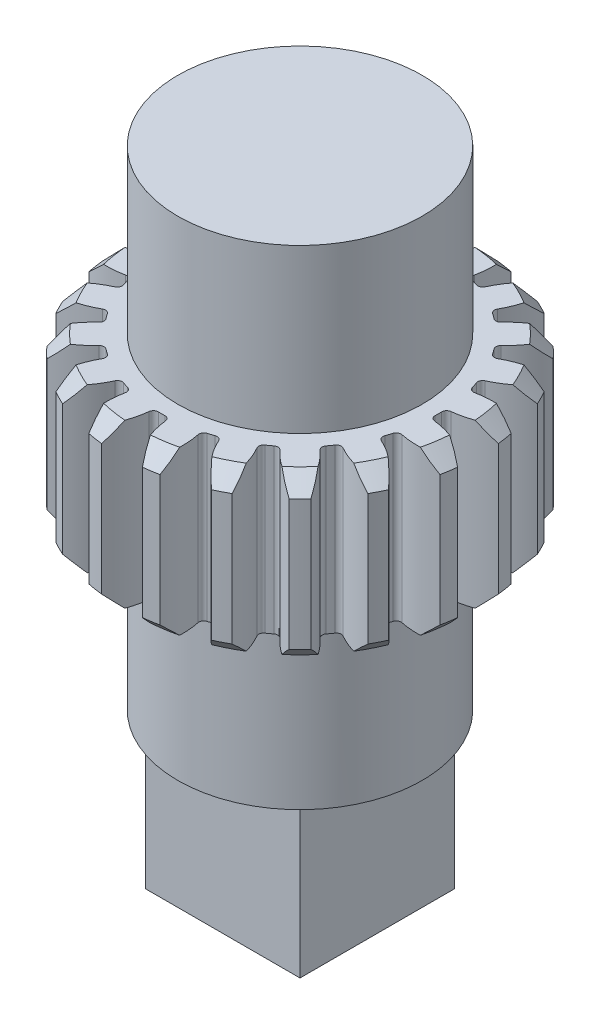
from build123d import *

# Parameters (mm, degrees)
SKETCH1_R                = 11
BOSS_EXTRUDE1_DEPTH      = 5
CUT_EXTRUDE4_DEPTH       = 6
FILLET1_R                = 0.3
CHAMFER1_SIZE            = 1
CIRPATTERN1_COUNT        = 20
FILLET1_OF_CIRPATTERN1_R = 0.3
SKETCH3_R                = 7.5
BOSS_EXTRUDE2_DEPTH      = 10
SKETCH6_R                = 7.5
BOSS_EXTRUDE3_DEPTH      = 10
SKETCH7_W                = 9.5
SKETCH7_H                = 9.5
BOSS_EXTRUDE4_DEPTH      = 9.5


with BuildPart() as part:
    # Sketch1 → Boss-Extrude1 (new body, symmetric)
    with BuildSketch(Plane(origin=(0, 0, 0), x_dir=(1, 0, 0), z_dir=(0, 1, 0))):
        Circle(SKETCH1_R)
    extrude(amount=BOSS_EXTRUDE1_DEPTH, both=True)

    # Sketch2 → Cut-Extrude4 (cut, symmetric)
    with BuildSketch(Plane(origin=(0, 0, 0), x_dir=(1, 0, 0), z_dir=(0, 1, 0))):
        with BuildLine():
            ThreePointArc((-1.250422517, 10.928698163), (-0.712144791, 9.755836403), (-0.479751903, 8.486450266))
            ThreePointArc((-0.479751903, 8.486450266), (0, 8.5), (0.479751903, 8.486450266))
            ThreePointArc((0.479751903, 8.486450266), (0.712144791, 9.755836403), (1.250422517, 10.928698163))
            ThreePointArc((1.250422517, 10.928698163), (0, 11), (-1.250422517, 10.928698163))
        make_face()
    cut_extrude4 = extrude(amount=CUT_EXTRUDE4_DEPTH, both=True, mode=Mode.SUBTRACT)

    # Fillet1
    fillet1_edges = [part.edges().sort_by_distance(p)[0] for p in [
        (0.479751903, 0, -8.486450266),
        (-0.479751903, 0, -8.486450266),
    ]]
    fillet(fillet1_edges, radius=FILLET1_R)

    # Chamfer1
    chamfer1_edges = [part.edges().sort_by_distance(p)[0] for p in [
        (0, -5, 11),
        (0, 5, 11),
    ]]
    chamfer(chamfer1_edges, length=CHAMFER1_SIZE)

    # CirPattern1: Cut-Extrude4 ×20 about axis
    cirpattern1_axis = Axis((0, 0, 0), (0, 1, 0))
    for i in range(1, CIRPATTERN1_COUNT):
        add(cut_extrude4.rotate(cirpattern1_axis, i * 360 / CIRPATTERN1_COUNT), mode=Mode.SUBTRACT)

    # Fillet1 of CirPattern1
    fillet1_of_cirpattern1_edges = [part.edges().sort_by_distance(p)[0] for p in [
        (-2.16618618, 0, -8.219345317),
        (-3.078728528, 0, -7.922842334),
        (-4.600082868, 0, -7.14767358),
        (-5.376337753, 0, -6.583691393),
        (-6.583691393, 0, -5.376337753),
        (-7.14767358, 0, -4.600082868),
        (-7.922842334, 0, -3.078728528),
        (-8.219345317, 0, -2.16618618),
        (-8.486450266, 0, -0.479751903),
        (-8.486450266, 0, 0.479751903),
        (-8.219345317, 0, 2.16618618),
        (-7.922842334, 0, 3.078728528),
        (-7.14767358, 0, 4.600082868),
        (-6.583691393, 0, 5.376337753),
        (-5.376337753, 0, 6.583691393),
        (-4.600082868, 0, 7.14767358),
        (-3.078728528, 0, 7.922842334),
        (-2.16618618, 0, 8.219345317),
        (-0.479751903, 0, 8.486450266),
        (0.479751903, 0, 8.486450266),
        (2.16618618, 0, 8.219345317),
        (3.078728528, 0, 7.922842334),
        (4.600082868, 0, 7.14767358),
        (5.376337753, 0, 6.583691393),
        (6.583691393, 0, 5.376337753),
        (7.14767358, 0, 4.600082868),
        (7.922842334, 0, 3.078728528),
        (8.219345317, 0, 2.16618618),
        (8.486450266, 0, 0.479751903),
        (8.486450266, 0, -0.479751903),
        (8.219345317, 0, -2.16618618),
        (7.922842334, 0, -3.078728528),
        (7.14767358, 0, -4.600082868),
        (6.583691393, 0, -5.376337753),
        (5.376337753, 0, -6.583691393),
        (4.600082868, 0, -7.14767358),
        (3.078728528, 0, -7.922842334),
        (2.16618618, 0, -8.219345317),
    ]]
    fillet(fillet1_of_cirpattern1_edges, radius=FILLET1_OF_CIRPATTERN1_R)

    # Sketch3 → Boss-Extrude2 (add)
    with BuildSketch(Plane(origin=(0, 5, 0), x_dir=(1, 0, 0), z_dir=(0, 1, 0))):
        Circle(SKETCH3_R)
    extrude(amount=BOSS_EXTRUDE2_DEPTH)

    # Sketch6 → Boss-Extrude3 (add)
    with BuildSketch(Plane.XZ.offset(5)):
        Circle(SKETCH6_R)
    extrude(amount=BOSS_EXTRUDE3_DEPTH)

    # Sketch7 → Boss-Extrude4 (add)
    with BuildSketch(Plane.XZ.offset(15)):
        Rectangle(SKETCH7_W, SKETCH7_H)
    extrude(amount=BOSS_EXTRUDE4_DEPTH)


solid = part.part
